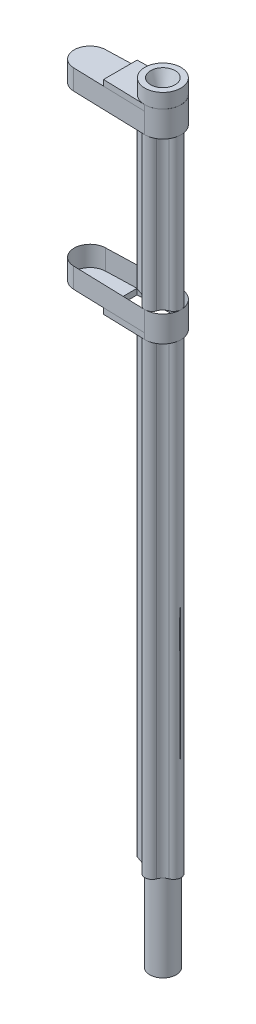
from build123d import *

# Parameters (mm, degrees)
SALIENTE_EXTRUIR2_DEPTH = 223
SALIENTE_EXTRUIR3_DEPTH = 7
SALIENTE_EXTRUIR4_DEPTH = 2
CROQUIS7_R              = 6.250085867
SALIENTE_EXTRUIR5_DEPTH = 5
CROQUIS8_R              = 4.25
CROQUIS9_R              = 1
CROQUIS10_R             = 4.57471759
SALIENTE_EXTRUIR6_DEPTH = 30


with BuildPart() as part:
    # Croquis1 → Saliente-Extruir2 (new body)
    with BuildSketch(Plane(origin=(0, 0, 0), x_dir=(1, 0, 0), z_dir=(0, 1, 0))):
        with BuildLine():
            Line((-14.479902674, 6.344412478), (-17.285197352, 5.373069954))
            ThreePointArc((-17.285197352, 5.373069954), (-18.294405629, 3.955634423), (-17.285197352, 2.538198891))
            Line((-17.285197352, 2.538198891), (-14.479902674, 1.566856368))
            ThreePointArc((-14.479902674, 1.566856368), (-13.134902489, 0.727156406), (-12.288428502, -0.61359089))
            ThreePointArc((-12.288428502, -0.61359089), (-9.893736846, -2.309516044), (-7.499045189, -0.61359089))
            ThreePointArc((-7.499045189, -0.61359089), (-6.663048477, 0.716688354), (-5.33552109, 1.557048043))
            ThreePointArc((-5.33552109, 1.557048043), (-3.642743095, 3.955634423), (-5.33552109, 6.354220802))
            ThreePointArc((-5.33552109, 6.354220802), (-6.654198374, 7.185732469), (-7.490653659, 8.501279498))
            ThreePointArc((-7.490653659, 8.501279498), (-9.893736846, 10.190483956), (-12.296820032, 8.501279498))
            ThreePointArc((-12.296820032, 8.501279498), (-13.143789356, 7.175301343), (-14.479902674, 6.344412478))
        make_face()
    extrude(amount=SALIENTE_EXTRUIR2_DEPTH)

    # Croquis5 → Saliente-Extruir3 (add)
    with BuildSketch(Plane(origin=(0, 223, 0), x_dir=(1, 0, 0), z_dir=(0, 1, 0))):
        with BuildLine():
            Line((-10.079327793, 10.188632247), (-35.332864115, 9.438053784))
            ThreePointArc((-35.332864115, 9.438053784), (-40.669466825, 3.940481472), (-35.332864115, -1.55709084))
            Line((-35.332864115, -1.55709084), (-10.079327793, -2.307669303))
            ThreePointArc((-10.079327793, -2.307669303), (-3.64271211, 3.940481472), (-10.079327793, 10.188632247))
        make_face()
    saliente_extruir3 = extrude(amount=SALIENTE_EXTRUIR3_DEPTH)

    # Croquis6 → Saliente-Extruir4 (add)
    with BuildSketch(Plane(origin=(0, 230, 0), x_dir=(1, 0, 0), z_dir=(0, 1, 0))):
        with BuildLine():
            Line((-24.6694675, 9.754988242), (-10.105220694, 10.18780896))
            ThreePointArc((-10.105220694, 10.18780896), (-3.64271211, 3.940481472), (-10.105220694, -2.306846016))
            Line((-10.105220694, -2.306846016), (-24.6694675, -1.874002597))
            Line((-24.6694675, -1.874002597), (-24.6694675, 9.754988242))
        make_face()
    saliente_extruir4 = extrude(amount=SALIENTE_EXTRUIR4_DEPTH)

    # Croquis7 → Saliente-Extruir5 (add)
    with BuildSketch(Plane(origin=(0, 232, 0), x_dir=(1, 0, 0), z_dir=(0, 1, 0))):
        with Locations((-9.919552693, 3.940481472)):
            Circle(CROQUIS7_R)
    extrude(amount=SALIENTE_EXTRUIR5_DEPTH)

    # Croquis8 → Cortar-Recubrir1 section 0
    with BuildSketch(Plane(origin=(0, 237, 0), x_dir=(1, 0, 0), z_dir=(0, 1, 0))):
        with Locations((-9.919552693, 3.940481472)):
            Circle(CROQUIS8_R)
    # Croquis9 → Cortar-Recubrir1 section 1
    with BuildSketch(Plane(origin=(0, 229, 0), x_dir=(1, 0, 0), z_dir=(0, 1, 0))):
        with Locations((-9.919552693, 3.940481472)):
            Circle(CROQUIS9_R)
    cortar_recubrir1 = loft(mode=Mode.SUBTRACT)

    # Simetría3: Saliente-Extruir3 across plane
    add(saliente_extruir3.mirror(Plane(origin=(0, 196.75, 0), x_dir=(0, 0, 1), z_dir=(0, -1, 0))))

    # Simetría4: Saliente-Extruir4 across plane
    add(saliente_extruir4.mirror(Plane(origin=(0, 196.75, 0), x_dir=(0, 0, 1), z_dir=(0, -1, 0))))

    # Croquis10 → Saliente-Extruir6 (add)
    with BuildSketch(Plane.XZ):
        with Locations((-9.893736846, -3.955634423)):
            Circle(CROQUIS10_R)
    extrude(amount=SALIENTE_EXTRUIR6_DEPTH)

    # Simetría5: Cortar-Recubrir1 across plane
    add(cortar_recubrir1.mirror(Plane(origin=(0, 103.5, 0), x_dir=(0, 0, 1), z_dir=(0, -1, 0))), mode=Mode.SUBTRACT)


solid = part.part
